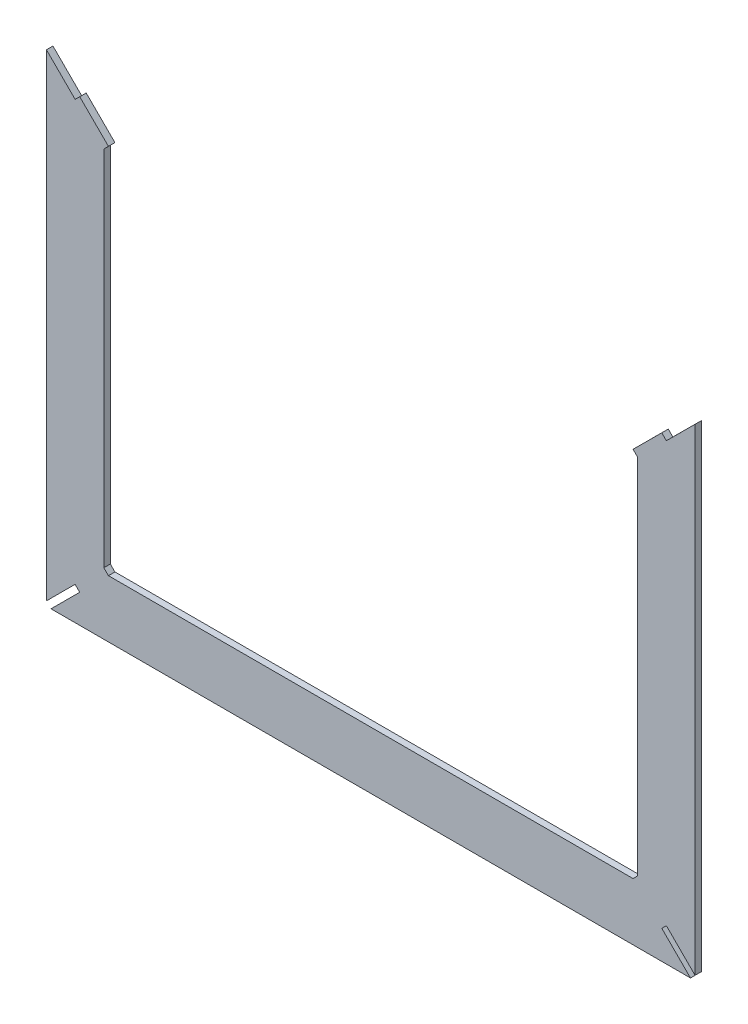
from build123d import *

# Parameters (mm, degrees)
BOSS_EXTRU_1_DEPTH = 4


with BuildPart() as part:
    # Esquisse1 → Boss.-Extru.1 (new body)
    with BuildSketch(Plane.XY):
        Polygon((-72.387865901, -137.132902491), (-69.559438777, -134.304475366), (-69.559438777, 89.31574626), (-72.384288507, 92.14774626), (-54.684288507, 109.803057076), (-51.859438777, 106.971057076), (-34.159438777, 124.626367892), (-34.159438777, -169.704475366), (-51.837108306, -152.026805837), (-54.665535431, -154.855232961), (-36.987865901, -172.532902491), (-431.331011652, -172.532902491), (-413.653342122, -154.855232961), (-416.481769247, -152.026805837), (-434.159438777, -169.704475366), (-434.159438777, 124.638670384), (-416.459438777, 106.983359568), (-413.634589046, 109.815359568), (-395.934589046, 92.160048753), (-398.759438777, 89.328048753), (-398.759438777, -134.304475366), (-395.931011652, -137.132902491), align=None)
    extrude(amount=BOSS_EXTRU_1_DEPTH)


solid = part.part
